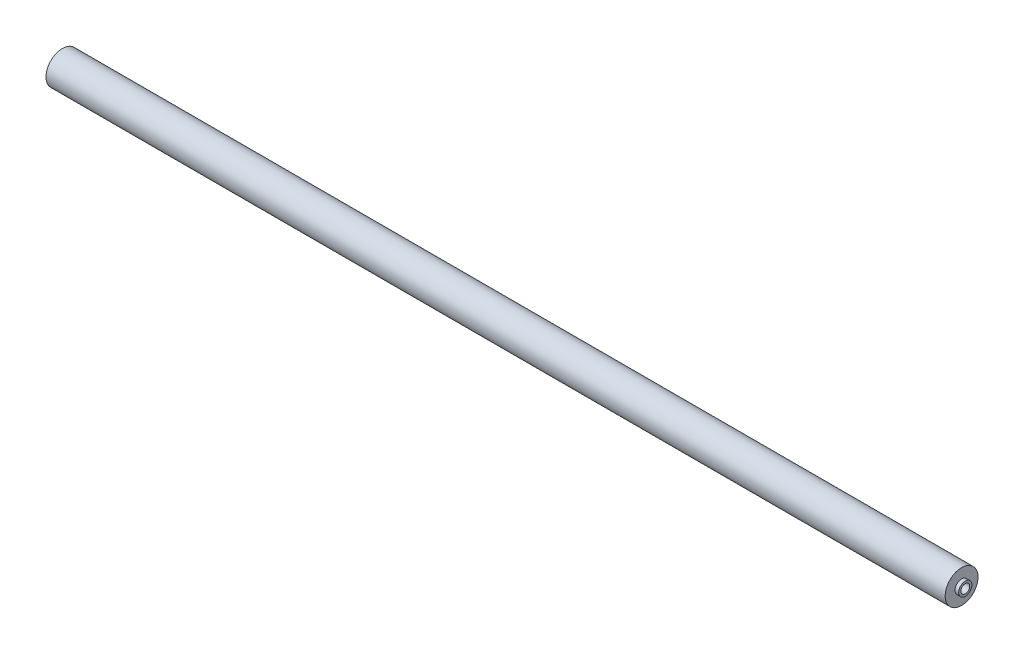
from build123d import *


with BuildPart() as part:
    # Sketch1 → Revolve1 (revolve)
    with BuildSketch(Plane.XY):
        Polygon((-610.1, 134.859540351), (-88.9, 134.859540351), (-88.9, 129.156209163), (-86.766722823, 129.156209163), (-86.766722823, 127.908151625), (-91.538056477, 127.908151625), (-93.361065656, 125.334540351), (-604.635283007, 125.334540351), (-605.901094644, 127.908151625), (-612.957851499, 127.908151625), (-612.957851499, 129.896410741), (-610.1, 129.896410741), align=None)
    revolve(axis=Axis((-669.436923845, 125.334540351, 0), (1, 0, 0)))


solid = part.part
